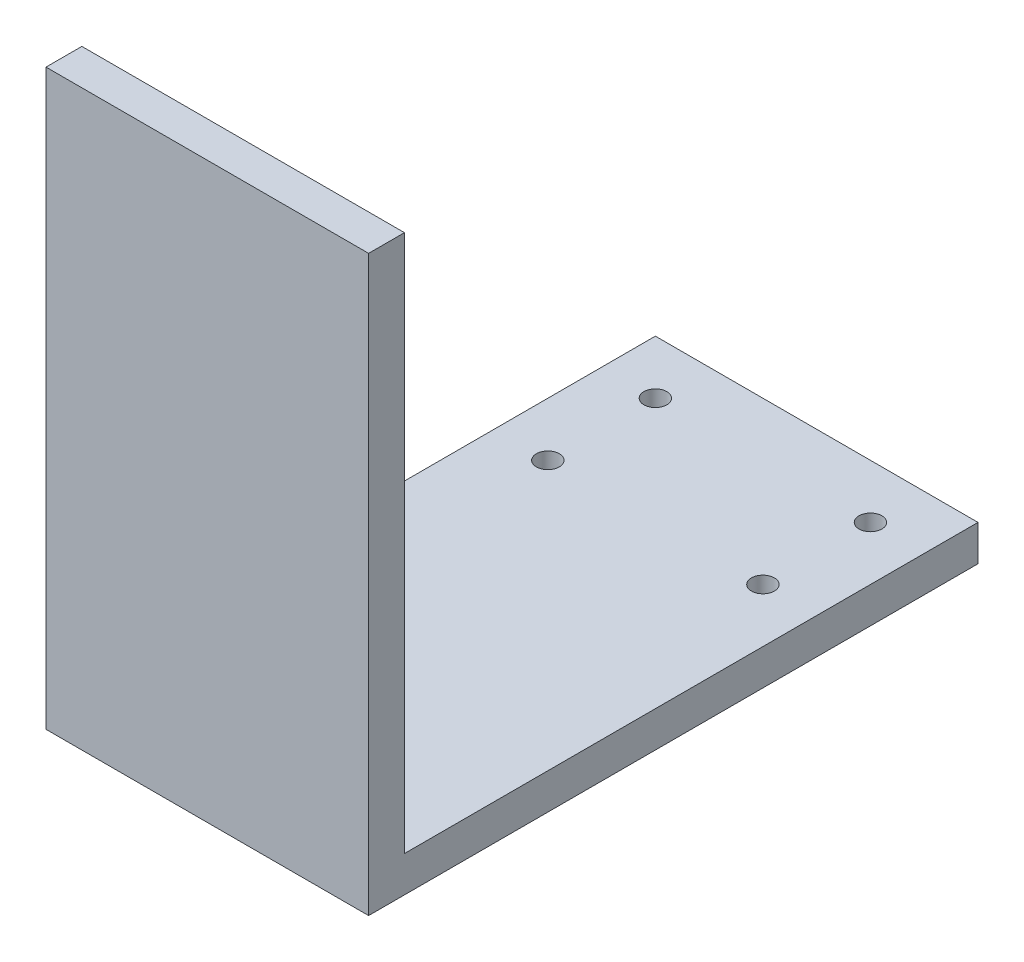
from build123d import *

# Parameters (mm, degrees)
SKETCH1_W           = 45
SKETCH1_H           = 30
BOSS_EXTRUDE1_DEPTH = 5
CUT_EXTRUDE1_REACH  = 7
SKETCH2_R           = 1.6
SKETCH4_W           = 45
SKETCH4_H           = 5
BOSS_EXTRUDE2_DEPTH = 55
SKETCH5_W           = 45
SKETCH5_H           = 5
BOSS_EXTRUDE3_DEPTH = 75


with BuildPart() as part:
    # Sketch1 → Boss-Extrude1 (new body)
    with BuildSketch(Plane(origin=(0, 0, 0), x_dir=(1, 0, 0), z_dir=(0, 1, 0))):
        Rectangle(SKETCH1_W, SKETCH1_H)
    extrude(amount=BOSS_EXTRUDE1_DEPTH)

    # Sketch2 → Cut-Extrude1 (cut, up to next)
    with BuildSketch(Plane(origin=(0, 0, 0), x_dir=(1, 0, 0), z_dir=(0, 1, 0)), mode=Mode.PRIVATE) as cut_extrude1_sk1:
        with Locations((-15, 7.5)):
            Circle(SKETCH2_R)
    cut_extrude1_tool1 = extrude(cut_extrude1_sk1.sketch, amount=CUT_EXTRUDE1_REACH, mode=Mode.PRIVATE) & part.part
    add(cut_extrude1_tool1.solids().sort_by_distance((-15, 0, -7.5))[0], mode=Mode.SUBTRACT)
    # Sketch2 → Cut-Extrude1 (cut, up to next)
    with BuildSketch(Plane(origin=(0, 0, 0), x_dir=(1, 0, 0), z_dir=(0, 1, 0)), mode=Mode.PRIVATE) as cut_extrude1_sk2:
        with Locations((15, 7.5)):
            Circle(SKETCH2_R)
    cut_extrude1_tool2 = extrude(cut_extrude1_sk2.sketch, amount=CUT_EXTRUDE1_REACH, mode=Mode.PRIVATE) & part.part
    add(cut_extrude1_tool2.solids().sort_by_distance((15, 0, -7.5))[0], mode=Mode.SUBTRACT)
    # Sketch2 → Cut-Extrude1 (cut, up to next)
    with BuildSketch(Plane(origin=(0, 0, 0), x_dir=(1, 0, 0), z_dir=(0, 1, 0)), mode=Mode.PRIVATE) as cut_extrude1_sk3:
        with Locations((15, -7.5)):
            Circle(SKETCH2_R)
    cut_extrude1_tool3 = extrude(cut_extrude1_sk3.sketch, amount=CUT_EXTRUDE1_REACH, mode=Mode.PRIVATE) & part.part
    add(cut_extrude1_tool3.solids().sort_by_distance((15, 0, 7.5))[0], mode=Mode.SUBTRACT)
    # Sketch2 → Cut-Extrude1 (cut, up to next)
    with BuildSketch(Plane(origin=(0, 0, 0), x_dir=(1, 0, 0), z_dir=(0, 1, 0)), mode=Mode.PRIVATE) as cut_extrude1_sk4:
        with Locations((-15, -7.5)):
            Circle(SKETCH2_R)
    cut_extrude1_tool4 = extrude(cut_extrude1_sk4.sketch, amount=CUT_EXTRUDE1_REACH, mode=Mode.PRIVATE) & part.part
    add(cut_extrude1_tool4.solids().sort_by_distance((-15, 0, 7.5))[0], mode=Mode.SUBTRACT)

    # Sketch4 → Boss-Extrude2 (add)
    with BuildSketch(Plane.XY.offset(15)):
        with Locations((0, 2.5)):
            Rectangle(SKETCH4_W, SKETCH4_H)
    extrude(amount=BOSS_EXTRUDE2_DEPTH)

    # Sketch5 → Boss-Extrude3 (add)
    with BuildSketch(Plane(origin=(0, 5, 0), x_dir=(1, 0, 0), z_dir=(0, 1, 0))):
        with Locations((0, -67.5)):
            Rectangle(SKETCH5_W, SKETCH5_H)
    extrude(amount=BOSS_EXTRUDE3_DEPTH)


solid = part.part
